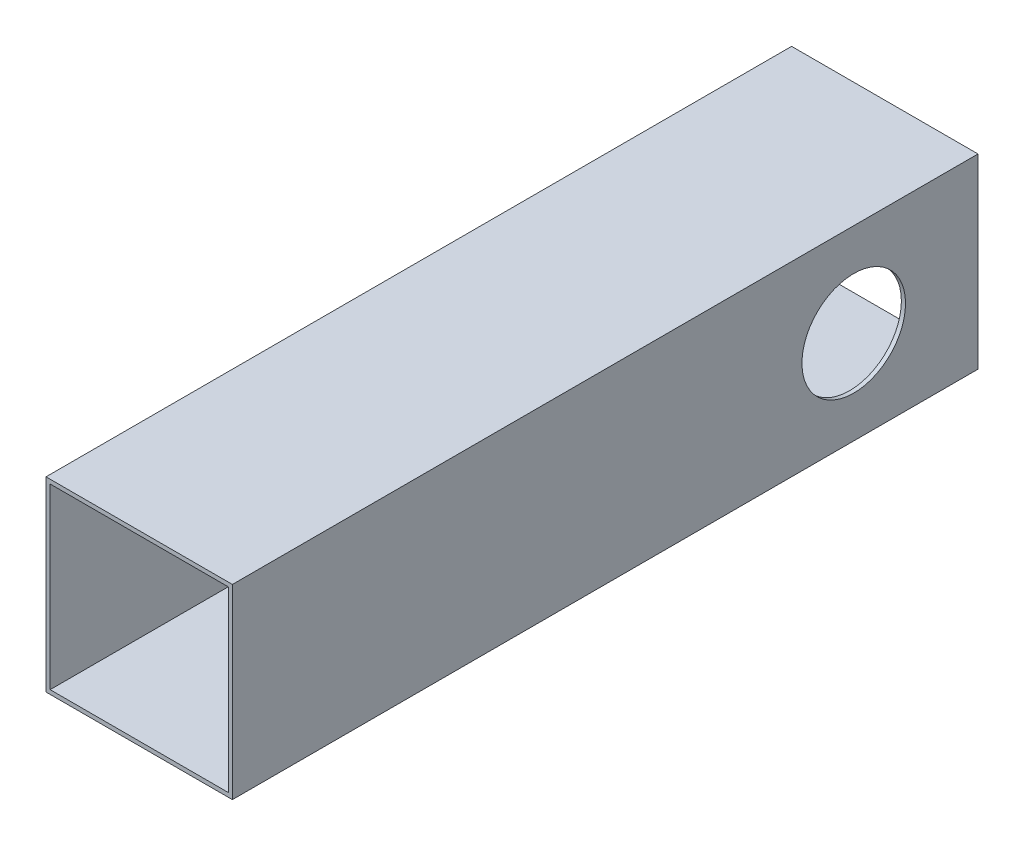
from build123d import *

# Parameters (mm, degrees)
SKETCH1_W           = 45
SKETCH1_H           = 45
SKETCH1_W_2         = 43
SKETCH1_H_2         = 43
BOSS_EXTRUDE1_DEPTH = 180
SKETCH2_R           = 12.5
CUT_EXTRUDE1_DEPTH  = 180


with BuildPart() as part:
    # Sketch1 → Boss-Extrude1 (new body)
    with BuildSketch(Plane.XY):
        Rectangle(SKETCH1_W, SKETCH1_H)
        Rectangle(SKETCH1_W_2, SKETCH1_H_2, mode=Mode.SUBTRACT)
    extrude(amount=BOSS_EXTRUDE1_DEPTH)

    # Sketch2 → Cut-Extrude1 (cut)
    with BuildSketch(Plane(origin=(22.5, 0, 0), x_dir=(0, 0, -1), z_dir=(1, 0, 0))):
        with Locations((-30, 0)):
            Circle(SKETCH2_R)
    extrude(amount=-CUT_EXTRUDE1_DEPTH, mode=Mode.SUBTRACT)


solid = part.part
